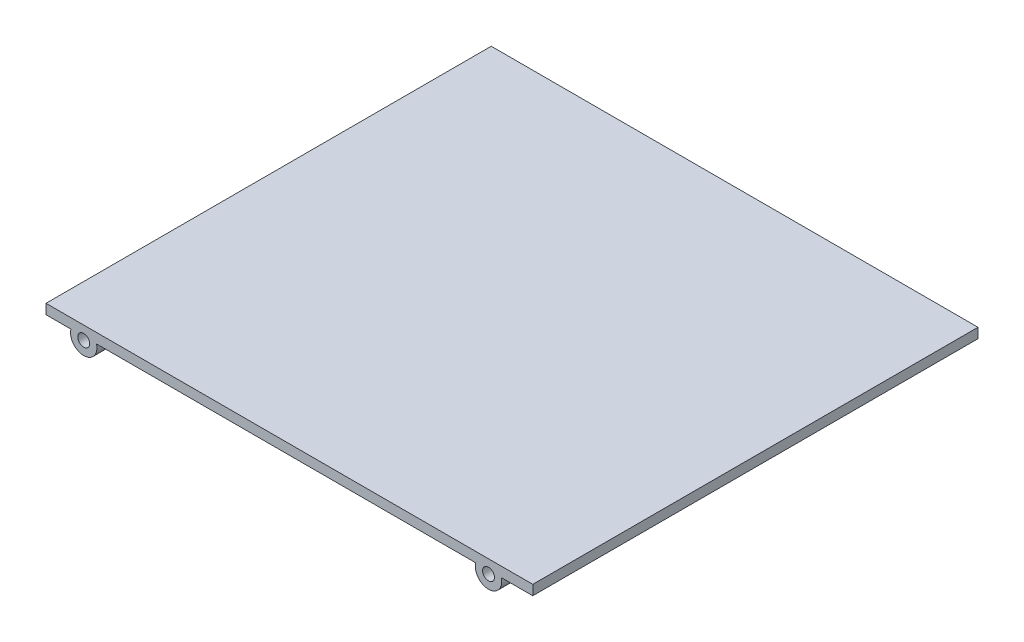
from build123d import *

# Parameters (mm, degrees)
SKETCH1_W           = 73.66656521
SKETCH1_H           = 1.5
BOSS_EXTRUDE1_DEPTH = 67.38
SKETCH2_R           = 2
BOSS_EXTRUDE2_DEPTH = 8
SKETCH3_R           = 0.9
CUT_EXTRUDE1_DEPTH  = 8
SKETCH4_R           = 2
BOSS_EXTRUDE3_DEPTH = 8
SKETCH5_R           = 0.9
CUT_EXTRUDE2_DEPTH  = 8


with BuildPart() as part:
    # Sketch1 → Boss-Extrude1 (new body)
    with BuildSketch(Plane.XY):
        with Locations((-252.623812979, 18.882492425)):
            Rectangle(SKETCH1_W, SKETCH1_H)
    extrude(amount=BOSS_EXTRUDE1_DEPTH)

    # Sketch2 → Boss-Extrude2 (add)
    with BuildSketch(Plane(origin=(0, 0, 0), x_dir=(-1, 0, 0), z_dir=(0, 0, -1))):
        with Locations((283.750452743, 17.632492425)):
            Circle(SKETCH2_R)
        with Locations((222.491552839, 17.632492425)):
            Circle(SKETCH2_R)
    extrude(amount=-BOSS_EXTRUDE2_DEPTH)

    # Sketch3 → Cut-Extrude1 (cut)
    with BuildSketch(Plane(origin=(0, 0, 0), x_dir=(-1, 0, 0), z_dir=(0, 0, -1))):
        with Locations((222.491552839, 17.632492425)):
            Circle(SKETCH3_R)
        with Locations((283.750452743, 17.632492425)):
            Circle(SKETCH3_R)
    extrude(amount=-CUT_EXTRUDE1_DEPTH, mode=Mode.SUBTRACT)

    # Sketch4 → Boss-Extrude3 (add)
    with BuildSketch(Plane.XY.offset(67.38)):
        with Locations((-222.491552839, 17.632492425)):
            Circle(SKETCH4_R)
        with Locations((-283.750452743, 17.632492425)):
            Circle(SKETCH4_R)
    extrude(amount=-BOSS_EXTRUDE3_DEPTH)

    # Sketch5 → Cut-Extrude2 (cut)
    with BuildSketch(Plane.XY.offset(67.38)):
        with Locations((-283.750452743, 17.632492425)):
            Circle(SKETCH5_R)
        with Locations((-222.491552839, 17.632492425)):
            Circle(SKETCH5_R)
    extrude(amount=-CUT_EXTRUDE2_DEPTH, mode=Mode.SUBTRACT)


solid = part.part
